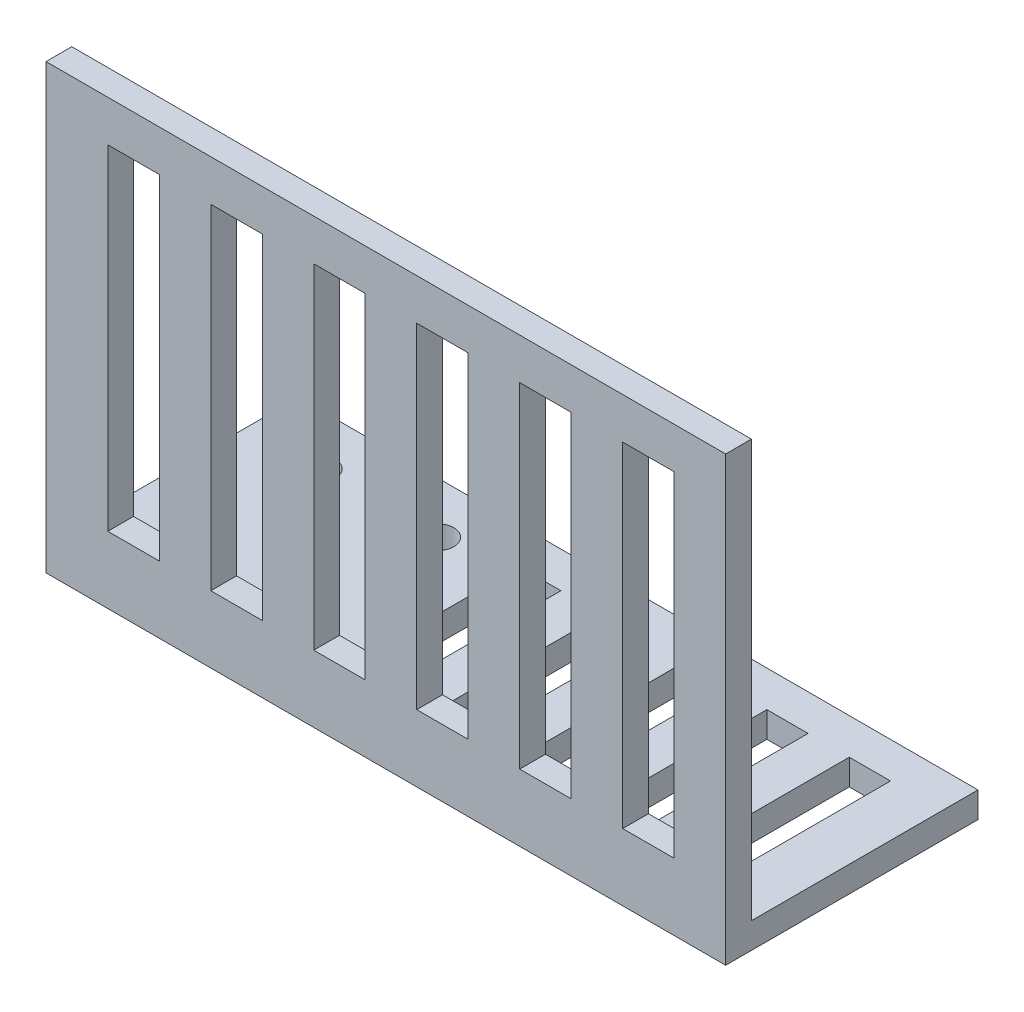
from build123d import *

# Parameters (mm, degrees)
SKETCH1_R           = 1.6
BOSS_EXTRUDE1_DEPTH = 2.5
SKETCH2_W           = 66
SKETCH2_H           = 2.5
BOSS_EXTRUDE2_DEPTH = 43
SKETCH3_W           = 5
SKETCH3_H           = 32.5
CUT_EXTRUDE1_DEPTH  = 9.5
LPATTERN1_COUNT     = 6
LPATTERN1_PITCH     = 10
SKETCH4_W           = 4
SKETCH4_H           = 15
CUT_EXTRUDE2_DEPTH  = 44
LPATTERN2_COUNT     = 5
LPATTERN2_PITCH     = 8


with BuildPart() as part:
    # Sketch1 → Boss-Extrude1 (new body)
    with BuildSketch(Plane(origin=(0, 0, 0), x_dir=(1, 0, 0), z_dir=(0, 1, 0))):
        Polygon((-33, 6), (-33, 16), (33, 16), (33, 6), (33, -6), (-33, -6), align=None)
        with Locations((-26, 11)):
            Circle(SKETCH1_R, mode=Mode.SUBTRACT)
        with Locations((-14.5, 11)):
            Circle(SKETCH1_R, mode=Mode.SUBTRACT)
    extrude(amount=BOSS_EXTRUDE1_DEPTH)

    # Sketch2 → Boss-Extrude2 (add)
    with BuildSketch(Plane(origin=(0, 0, 0), x_dir=(1, 0, 0), z_dir=(0, 1, 0))):
        with Locations((0, -7.25)):
            Rectangle(SKETCH2_W, SKETCH2_H)
    extrude(amount=BOSS_EXTRUDE2_DEPTH)

    # Sketch3 → Cut-Extrude1 (cut, through all)
    with BuildSketch(Plane.XY):
        with Locations((25.5, 22.75)):
            Rectangle(SKETCH3_W, SKETCH3_H)
    cut_extrude1 = extrude(amount=CUT_EXTRUDE1_DEPTH, mode=Mode.SUBTRACT)

    # LPattern1: Cut-Extrude1 ×6
    with Locations(*[(-i * LPATTERN1_PITCH, 0, 0) for i in range(1, LPATTERN1_COUNT)]):
        add(cut_extrude1, mode=Mode.SUBTRACT)

    # Sketch4 → Cut-Extrude2 (cut, through all)
    with BuildSketch(Plane(origin=(0, 0, 0), x_dir=(1, 0, 0), z_dir=(0, 1, 0))):
        with Locations((26, 5)):
            Rectangle(SKETCH4_W, SKETCH4_H)
    cut_extrude2 = extrude(amount=CUT_EXTRUDE2_DEPTH, mode=Mode.SUBTRACT)

    # LPattern2: Cut-Extrude2 ×5
    with Locations(*[(-i * LPATTERN2_PITCH, 0, 0) for i in range(1, LPATTERN2_COUNT)]):
        add(cut_extrude2, mode=Mode.SUBTRACT)


solid = part.part
